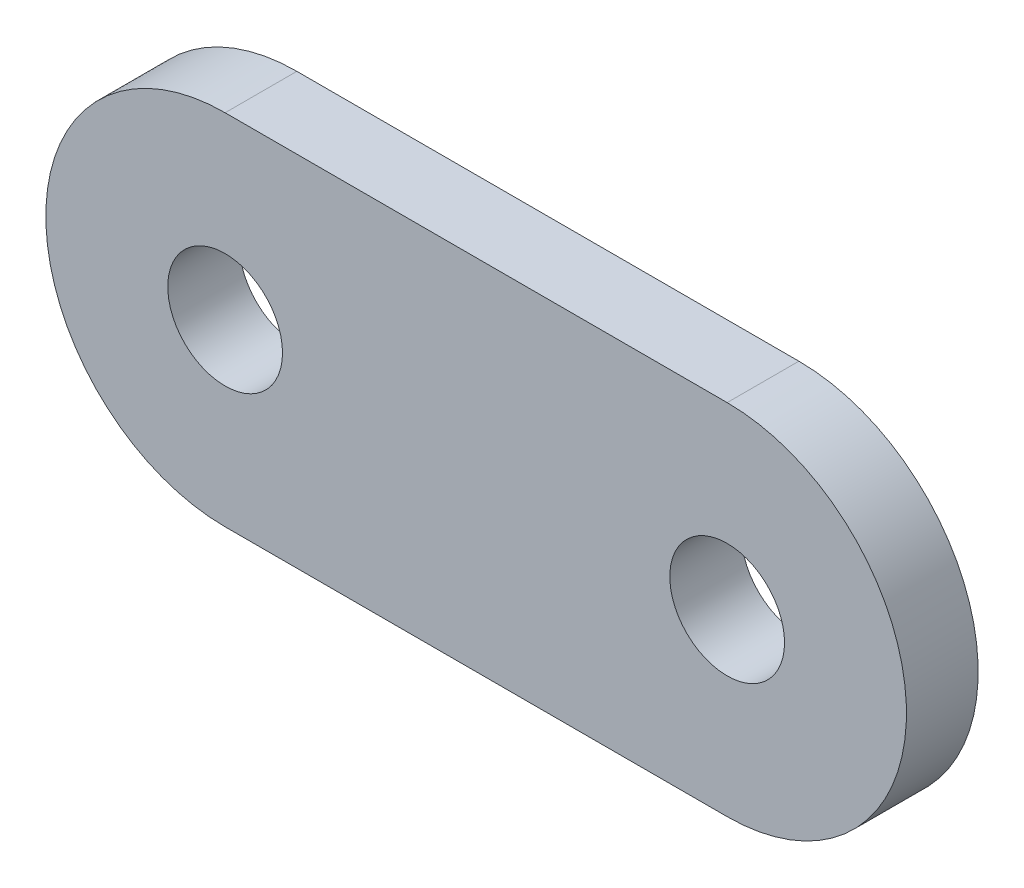
from build123d import *

# Parameters (mm, degrees)
ESBO_O1_R                = 1.6
RESSALTO_EXTRUS_O1_DEPTH = 2


with BuildPart() as part:
    # Esboço1 → Ressalto-extrusão1 (new body)
    with BuildSketch(Plane.XY):
        with BuildLine():
            Line((-7, 5), (7, 5))
            ThreePointArc((7, 5), (12, 0), (7, -5))
            Line((7, -5), (-7, -5))
            ThreePointArc((-7, -5), (-12, 0), (-7, 5))
        make_face()
        with Locations((7, 0)):
            Circle(ESBO_O1_R, mode=Mode.SUBTRACT)
        with Locations((-7, 0)):
            Circle(ESBO_O1_R, mode=Mode.SUBTRACT)
    extrude(amount=RESSALTO_EXTRUS_O1_DEPTH)


solid = part.part
